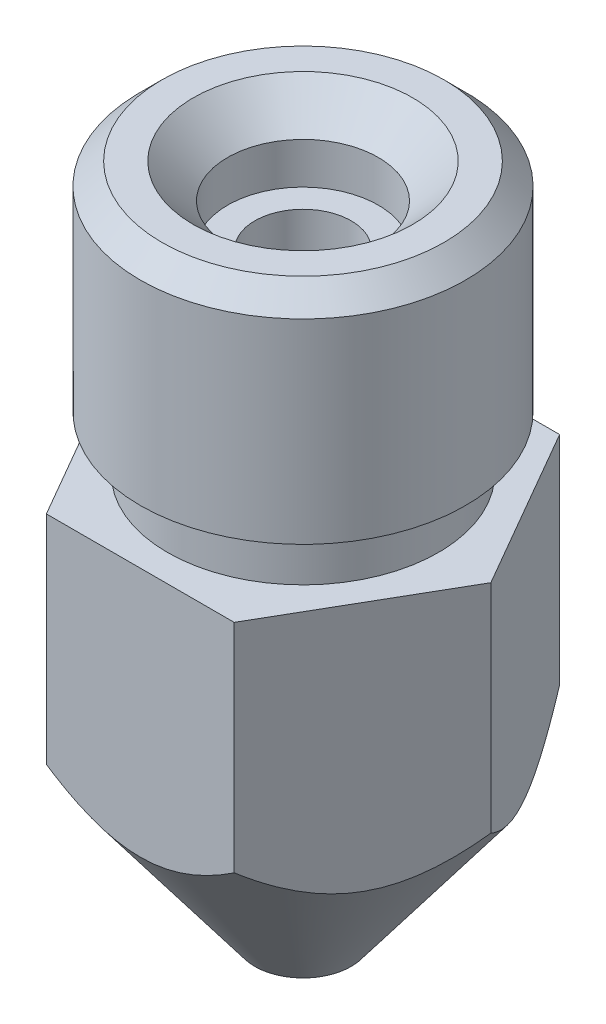
from build123d import *

# Parameters (mm, degrees)
SKETCH2_R           = 3
BOSS_EXTRUDE1_DEPTH = 13
BOSS_EXTRUDE2_DEPTH = 8
SKETCH6_R           = 3
SKETCH6_R_2         = 2.5
CUT_EXTRUDE1_DEPTH  = 1
CHAMFER1_SIZE       = 0.4
SKETCH7_R           = 0.2
CUT_EXTRUDE2_DEPTH  = 14


with BuildPart() as part:
    # Sketch2 → Boss-Extrude1 (new body)
    with BuildSketch(Plane(origin=(0, 0, 0), x_dir=(1, 0, 0), z_dir=(0, 1, 0))):
        Circle(SKETCH2_R)
    extrude(amount=BOSS_EXTRUDE1_DEPTH)

    # Sketch3 → Boss-Extrude2 (add)
    with BuildSketch(Plane.XZ):
        Polygon((1.732050808, -3), (3.464101615, 0), (1.732050808, 3), (-1.732050808, 3), (-3.464101615, 0), (-1.732050808, -3), align=None)
    extrude(amount=-BOSS_EXTRUDE2_DEPTH)

    # Sketch4 → Cut-Revolve3 (revolve, cut)
    with BuildSketch(Plane.XY):
        Polygon((-0.45, 0), (-3.464101615, 4), (-3.464101615, 0), align=None)
    revolve(axis=Axis((0, 0, 0), (0, 1, 0)), mode=Mode.SUBTRACT)

    # Sketch6 → Cut-Extrude1 (cut)
    with BuildSketch(Plane(origin=(0, 8, 0), x_dir=(1, 0, 0), z_dir=(0, 1, 0))):
        Circle(SKETCH6_R)
        Circle(SKETCH6_R_2, mode=Mode.SUBTRACT)
    extrude(amount=CUT_EXTRUDE1_DEPTH, mode=Mode.SUBTRACT)

    # Chamfer1
    chamfer1_edges = [part.edges().sort_by_distance(p)[0] for p in [
        (-3, 13, 0),
    ]]
    chamfer(chamfer1_edges, length=CHAMFER1_SIZE)

    # Sketch7 → Cut-Extrude2 (cut, through all)
    with BuildSketch(Plane.XZ):
        Circle(SKETCH7_R)
    extrude(amount=-CUT_EXTRUDE2_DEPTH, mode=Mode.SUBTRACT)

    # Sketch9 → CBORE for #0 Fillister Head Machine Screw1 (revolve, cut)
    with BuildSketch(Plane(origin=(0, 13, 0), x_dir=(0, 0, 1), z_dir=(1, 0, 0))):
        Polygon((0, 0), (0, 13), (0.889, 13), (0.889, 1.397), (1.38938, 1.397), (1.38938, 0.635), (2.02438, 0), align=None)
    revolve(axis=Axis((0, 19.35, 0), (0, -1, 0)), mode=Mode.SUBTRACT)


solid = part.part
